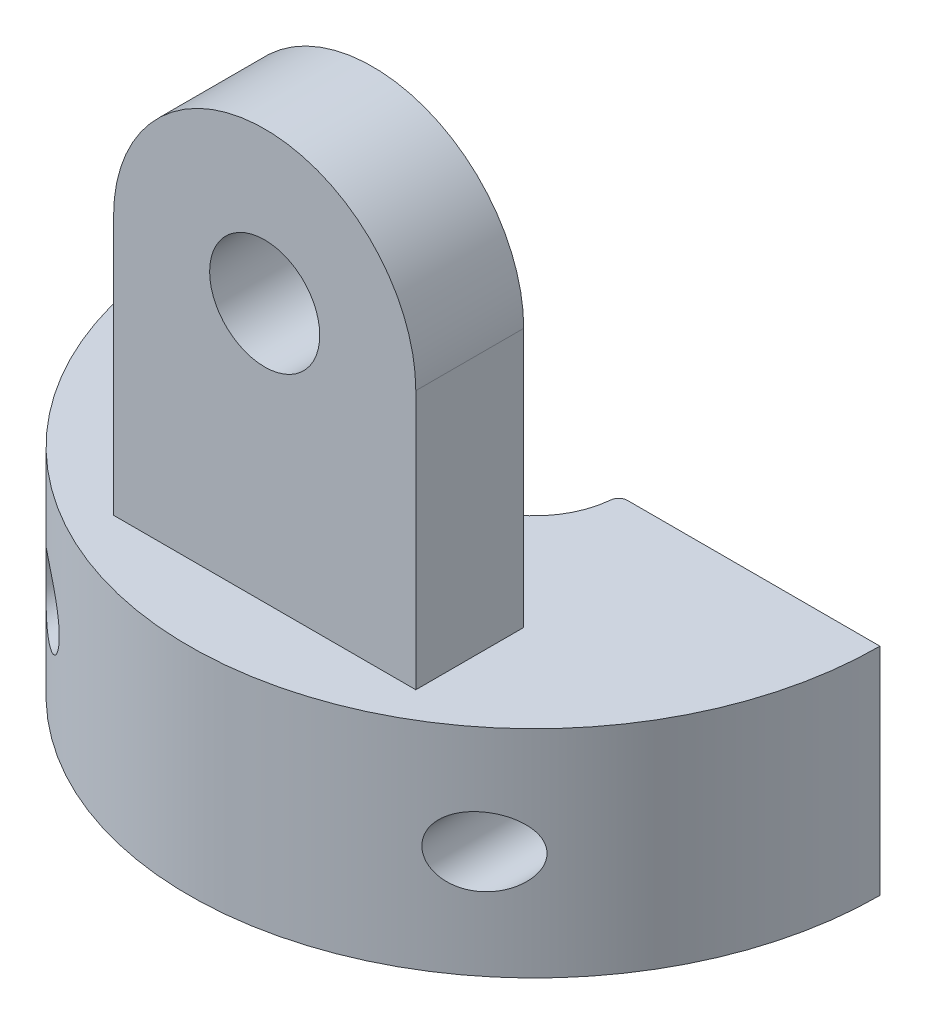
from build123d import *

# Parameters (mm, degrees)
BOSS_EXTRUDE1_DEPTH   = 2.5
SKETCH2_W             = 7
SKETCH2_H             = 2.5
BOSS_EXTRUDE2_DEPTH   = 9.5
CUT_EXTRUDE1_DEPTH    = 9.5
SKETCH4_R             = 1.275
CUT_EXTRUDE2_DEPTH    = 9.5
M2X0_4_TAPPED_HOLE1_D = 1.6
FILLET1_R             = 0.2


with BuildPart() as part:
    # Sketch1 → Boss-Extrude1 (new body, symmetric)
    with BuildSketch(Plane(origin=(0, 0, 0), x_dir=(1, 0, 0), z_dir=(0, 1, 0))):
        with BuildLine():
            Line((1.96, 0), (8, 0))
            ThreePointArc((8, 0), (0, -8), (-8, 0))
            Line((-8, 0), (-1.96, 0))
            ThreePointArc((-1.96, 0), (0, -1.96), (1.96, 0))
        make_face()
    extrude(amount=BOSS_EXTRUDE1_DEPTH, both=True)

    # Sketch2 → Boss-Extrude2 (add)
    with BuildSketch(Plane(origin=(0, 2.5, 0), x_dir=(1, 0, 0), z_dir=(0, 1, 0))):
        with Locations((0, -5)):
            Rectangle(SKETCH2_W, SKETCH2_H)
    extrude(amount=BOSS_EXTRUDE2_DEPTH)

    # Sketch3 → Cut-Extrude1 (cut)
    with BuildSketch(Plane(origin=(0, 0, 3.75), x_dir=(-1, 0, 0), z_dir=(0, 0, -1))):
        with BuildLine():
            Line((-3.5, 8.5), (-3.5, 14.886359519))
            Line((-3.5, 14.886359519), (0, 16.809201746))
            Line((0, 16.809201746), (3.5, 14.5))
            Line((3.5, 14.5), (3.5, 8.5))
            ThreePointArc((3.5, 8.5), (0, 12), (-3.5, 8.5))
        make_face()
    extrude(amount=-CUT_EXTRUDE1_DEPTH, mode=Mode.SUBTRACT)

    # Sketch4 → Cut-Extrude2 (cut)
    with BuildSketch(Plane(origin=(0, 0, 3.75), x_dir=(-1, 0, 0), z_dir=(0, 0, -1))):
        with Locations((0, 8.5)):
            Circle(SKETCH4_R)
    extrude(amount=-CUT_EXTRUDE2_DEPTH, mode=Mode.SUBTRACT)

    # M2x0.4 Tapped Hole1 (through all)
    with Locations(Plane(origin=(0, 0, 0), x_dir=(-1, 0, 0), z_dir=(0, 0, -1))):
        with Locations((-5, 0), (5, 0)):
            Hole(M2X0_4_TAPPED_HOLE1_D / 2)

    # Fillet1
    fillet1_edges = [part.edges().sort_by_distance(p)[0] for p in [
        (1.96, 0, 0),
        (-1.96, 0, 0),
    ]]
    fillet(fillet1_edges, radius=FILLET1_R)


solid = part.part
